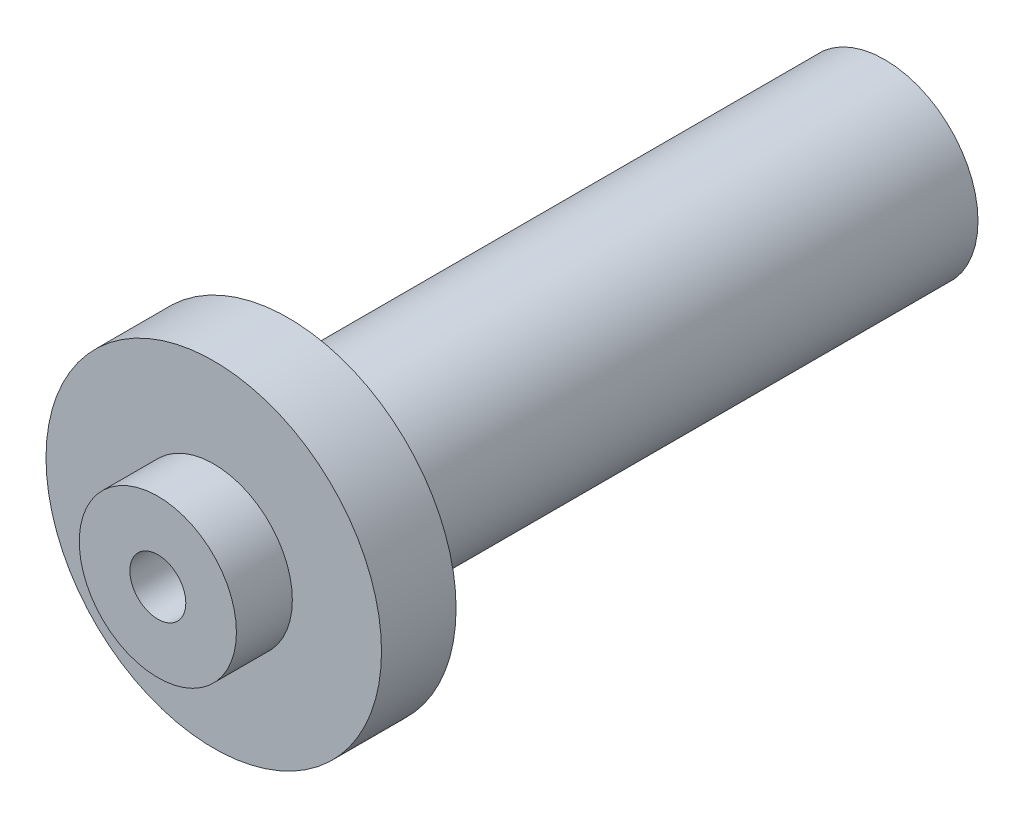
from build123d import *

# Parameters (mm, degrees)
SKETCH3_R           = 31.75
BOSS_EXTRUDE1_DEPTH = 203.2
SKETCH4_R           = 57.15
BOSS_EXTRUDE2_DEPTH = 25.4
SKETCH5_R           = 26.7716
BOSS_EXTRUDE3_DEPTH = 19.05
SKETCH6_R           = 9.525
CUT_EXTRUDE1_DEPTH  = 248.65


with BuildPart() as part:
    # Sketch3 → Boss-Extrude1 (new body)
    with BuildSketch(Plane.XY):
        Circle(SKETCH3_R)
    extrude(amount=BOSS_EXTRUDE1_DEPTH)

    # Sketch4 → Boss-Extrude2 (add)
    with BuildSketch(Plane.XY.offset(203.2)):
        Circle(SKETCH4_R)
    extrude(amount=BOSS_EXTRUDE2_DEPTH)

    # Sketch5 → Boss-Extrude3 (add)
    with BuildSketch(Plane.XY.offset(228.6)):
        Circle(SKETCH5_R)
    extrude(amount=BOSS_EXTRUDE3_DEPTH)

    # Sketch6 → Cut-Extrude1 (cut, through all)
    with BuildSketch(Plane.XY.offset(247.65)):
        Circle(SKETCH6_R)
    extrude(amount=-CUT_EXTRUDE1_DEPTH, mode=Mode.SUBTRACT)


solid = part.part
